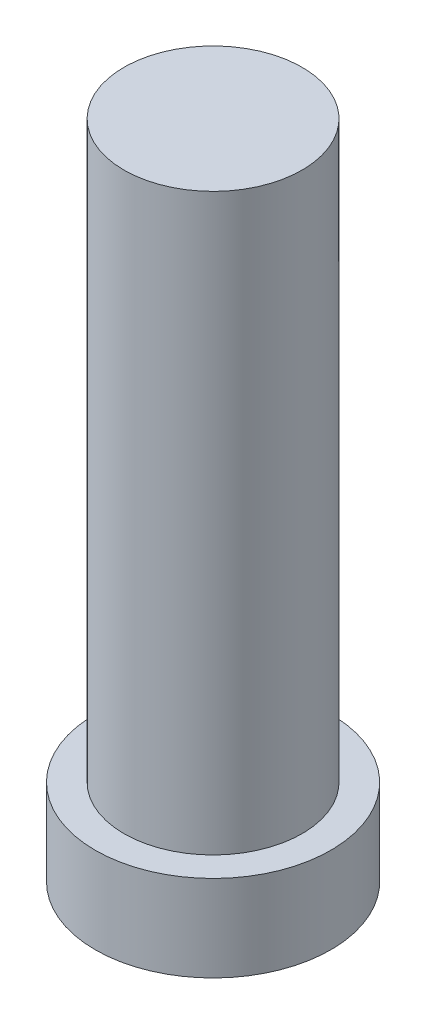
from build123d import *

# Parameters (mm, degrees)
SKETCH1_R           = 5.207
BOSS_EXTRUDE1_DEPTH = 3.81
SKETCH2_R           = 3.937
BOSS_EXTRUDE2_DEPTH = 25.4


with BuildPart() as part:
    # Sketch1 → Boss-Extrude1 (new body)
    with BuildSketch(Plane(origin=(0, 0, 0), x_dir=(1, 0, 0), z_dir=(0, 1, 0))):
        Circle(SKETCH1_R)
    extrude(amount=BOSS_EXTRUDE1_DEPTH)

    # Sketch2 → Boss-Extrude2 (add)
    with BuildSketch(Plane(origin=(0, 3.81, 0), x_dir=(1, 0, 0), z_dir=(0, 1, 0))):
        Circle(SKETCH2_R)
    extrude(amount=BOSS_EXTRUDE2_DEPTH)


solid = part.part
